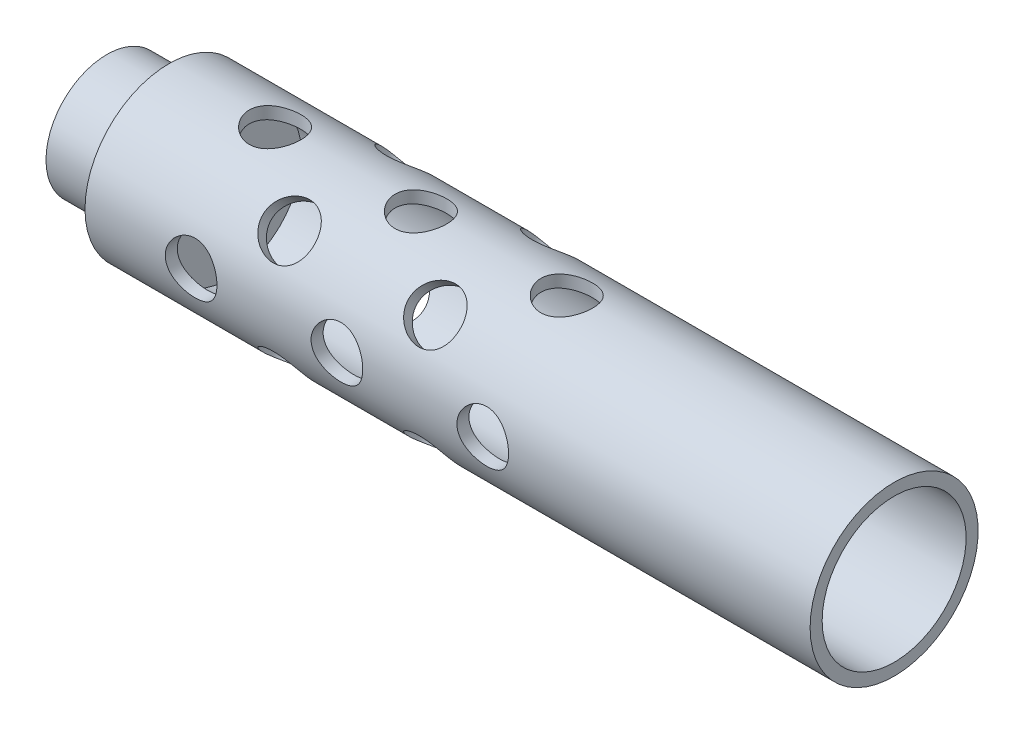
from build123d import *

# Parameters (mm, degrees)
SKETCH3_R          = 7
CUT_EXTRUDE2_DEPTH = 50
CIRPATTERN2_COUNT  = 4
SKETCH4_R          = 7
CUT_EXTRUDE3_DEPTH = 50
CIRPATTERN3_COUNT  = 4


with BuildPart() as part:
    # Sketch1 → Revolve1 (revolve)
    with BuildSketch(Plane.XY):
        Polygon((-106.62, 0), (-106.62, 16.5), (-89.8, 16.5), (-89.8, 22.76), (106.62, 22.76), (106.62, 19.5), (-73.38, 19.5), (-73.38, 0), align=None)
    revolve(axis=Axis((-106.62, 0, 0), (1, 0, 0)))

    # Sketch3 → Cut-Extrude2 (cut, symmetric)
    with BuildSketch(Plane(origin=(0, 0, 0), x_dir=(1, 0, 0), z_dir=(0, 1, 0))):
        with Locations((17.94, 0)):
            Circle(SKETCH3_R)
        with Locations((-21.56, 0)):
            Circle(SKETCH3_R)
        with Locations((-61.06, 0)):
            Circle(SKETCH3_R)
    cut_extrude2 = extrude(amount=CUT_EXTRUDE2_DEPTH, both=True, mode=Mode.SUBTRACT)

    # CirPattern2: Cut-Extrude2 ×4 about axis
    cirpattern2_axis = Axis((-89.8, 0, 0), (-1, 0, 0))
    for i in range(1, CIRPATTERN2_COUNT):
        add(cut_extrude2.rotate(cirpattern2_axis, i * 360 / CIRPATTERN2_COUNT), mode=Mode.SUBTRACT)

    # Sketch4 → Cut-Extrude3 (cut, symmetric)
    with BuildSketch(Plane(origin=(0, 0, 0), x_dir=(-1, 0, 0), z_dir=(0, 0.7071067811865464, -0.7071067811865488))):
        with Locations((1.81, 0)):
            Circle(SKETCH4_R)
        with Locations((41.31, 0)):
            Circle(SKETCH4_R)
    cut_extrude3 = extrude(amount=CUT_EXTRUDE3_DEPTH, both=True, mode=Mode.SUBTRACT)

    # CirPattern3: Cut-Extrude3 ×4 about axis
    cirpattern3_axis = Axis((-89.8, 0, 0), (-1, 0, 0))
    for i in range(1, CIRPATTERN3_COUNT):
        add(cut_extrude3.rotate(cirpattern3_axis, i * 360 / CIRPATTERN3_COUNT), mode=Mode.SUBTRACT)


solid = part.part
